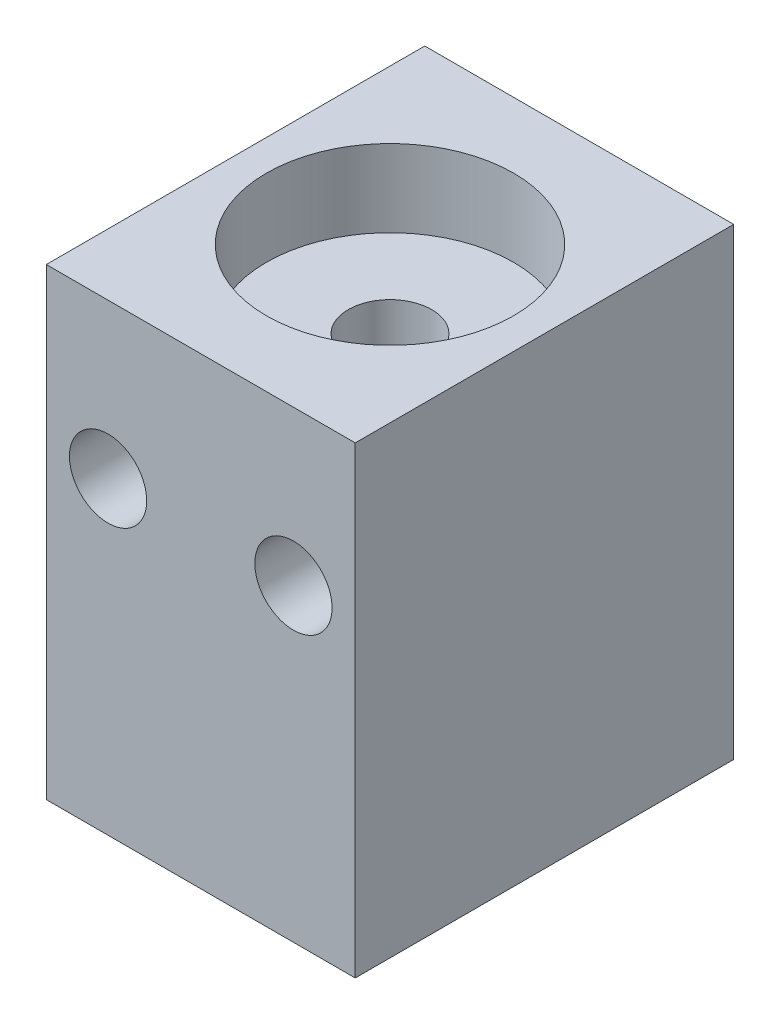
from build123d import *

# Parameters (mm, degrees)
SKETCH1_W           = 20
SKETCH1_H           = 30
BOSS_EXTRUDE1_DEPTH = 12.25
SKETCH4_R           = 2.5
CUT_EXTRUDE1_DEPTH  = 25.5


with BuildPart() as part:
    # Sketch1 → Boss-Extrude1 (new body, symmetric)
    with BuildSketch(Plane.XY):
        Rectangle(SKETCH1_W, SKETCH1_H)
    extrude(amount=BOSS_EXTRUDE1_DEPTH, both=True)

    # Sketch3 → Cut-Revolve1 (revolve, cut)
    with BuildSketch(Plane(origin=(0, 0, 0), x_dir=(0, 0, -1), z_dir=(1, 0, 0))):
        Polygon((0, 15), (0, -15), (8, -15), (8, -10), (2.7, -10), (2.7, 10), (8, 10), (8, 15), align=None)
    revolve(axis=Axis((0, 15, 0), (0, -1, 0)), mode=Mode.SUBTRACT)

    # Sketch4 → Cut-Extrude1 (cut, through all)
    with BuildSketch(Plane(origin=(0, 0, -12.25), x_dir=(-1, 0, 0), z_dir=(0, 0, -1))):
        with Locations((-6, 5)):
            Circle(SKETCH4_R)
        with Locations((6, 5)):
            Circle(SKETCH4_R)
    extrude(amount=-CUT_EXTRUDE1_DEPTH, mode=Mode.SUBTRACT)


solid = part.part
